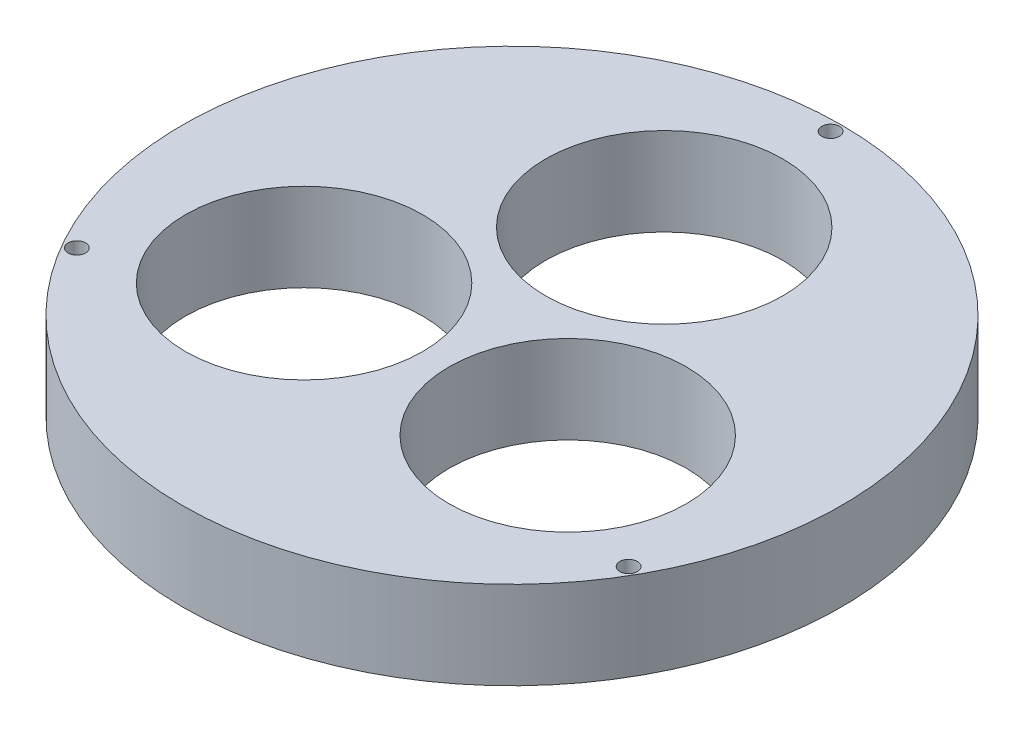
from build123d import *

# Parameters (mm, degrees)
SKETCH1_R           = 37.5
SKETCH1_R_2         = 13.5
SKETCH1_R_3         = 1
BOSS_EXTRUDE3_DEPTH = 10


with BuildPart() as part:
    # Sketch1 → Boss-Extrude3 (new body)
    with BuildSketch(Plane(origin=(0, 0, 0), x_dir=(1, 0, 0), z_dir=(0, 1, 0))):
        Circle(SKETCH1_R)
        with Locations((14.999559994, -8.66)):
            Circle(SKETCH1_R_2, mode=Mode.SUBTRACT)
        with Locations((0, 17.32)):
            Circle(SKETCH1_R_2, mode=Mode.SUBTRACT)
        with Locations((-14.999559994, -8.66)):
            Circle(SKETCH1_R_2, mode=Mode.SUBTRACT)
        with Locations((31.393420887, -18.125)):
            Circle(SKETCH1_R_3, mode=Mode.SUBTRACT)
        with Locations((0, 36.25)):
            Circle(SKETCH1_R_3, mode=Mode.SUBTRACT)
        with Locations((-31.393420887, -18.125)):
            Circle(SKETCH1_R_3, mode=Mode.SUBTRACT)
    extrude(amount=BOSS_EXTRUDE3_DEPTH)


solid = part.part
